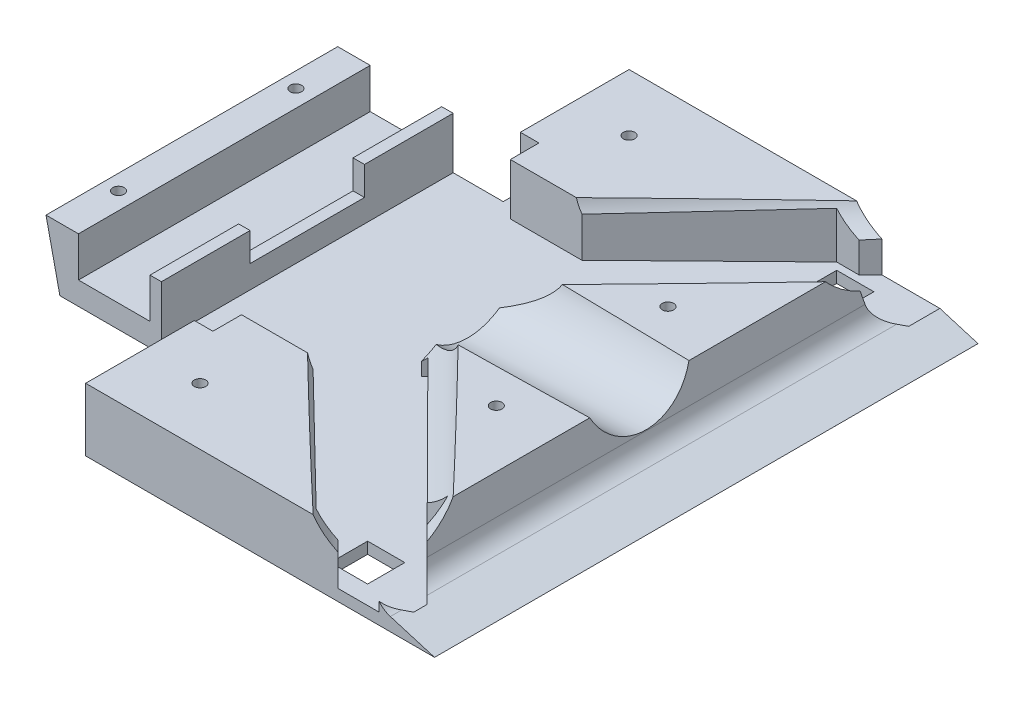
from build123d import *

# Parameters (mm, degrees)
SKETCH1_W           = 95
SKETCH1_H           = 95
BOSS_EXTRUDE1_DEPTH = 50
CUT_EXTRUDE1_DEPTH  = 100
SKETCH3_R           = 9.5
CUT_EXTRUDE2_DEPTH  = 45
CUT_EXTRUDE4_DEPTH  = 45
CUT_EXTRUDE5_DEPTH  = 45
CUT_EXTRUDE6_DEPTH  = 45
CUT_EXTRUDE7_DEPTH  = 45
SKETCH9_R           = 9.5
CUT_EXTRUDE9_DEPTH  = 45
SKETCH11_R          = 9.5
CUT_EXTRUDE10_DEPTH = 45
SKETCH12_W          = 31.985759797
SKETCH12_H          = 95
BOSS_EXTRUDE2_DEPTH = 45
CUT_EXTRUDE11_DEPTH = 100
SKETCH14_R          = 9.5
CUT_EXTRUDE12_DEPTH = 100
SKETCH15_R          = 9.5
CUT_EXTRUDE13_DEPTH = 100
SKETCH16_R          = 9.5
CUT_EXTRUDE14_DEPTH = 100
FILLET2_R           = 4
SKETCH17_W          = 34
SKETCH17_H          = 34
CUT_EXTRUDE16_DEPTH = 22
SKETCH19_W          = 34
SKETCH19_H          = 34
CUT_EXTRUDE17_DEPTH = 22
SKETCH20_W          = 12.5
SKETCH20_H          = 16.5
CUT_EXTRUDE18_DEPTH = 60
CUT_EXTRUDE19_DEPTH = 60
CUT_EXTRUDE20_DEPTH = 100
SKETCH23_W          = 96.786059211
SKETCH23_H          = 3
CUT_EXTRUDE21_DEPTH = 1090
CUT_EXTRUDE23_DEPTH = 9
SKETCH26_W          = 101.242795937
SKETCH26_H          = 23.181109139
CUT_EXTRUDE24_DEPTH = 1212
SKETCH27_W          = 9
SKETCH27_H          = 14
CUT_EXTRUDE25_DEPTH = 9
CUT_EXTRUDE30_DEPTH = 9
SKETCH33_W          = 5
SKETCH33_H          = 5
CUT_EXTRUDE31_DEPTH = 9
SKETCH34_W          = 11.575223562
SKETCH34_H          = 33.130685917
CUT_EXTRUDE32_DEPTH = 9
SKETCH35_W          = 15
SKETCH35_H          = 47
CUT_EXTRUDE33_DEPTH = 9
SKETCH36_W          = 1.386035128
SKETCH36_H          = 33.130685917
CUT_EXTRUDE34_DEPTH = 9
SKETCH37_W          = 2
SKETCH37_H          = 20
CUT_EXTRUDE35_DEPTH = 5
SKETCH38_R          = 1
CUT_EXTRUDE36_DEPTH = 5
SKETCH39_R          = 1
CUT_EXTRUDE37_DEPTH = 5
CUT_EXTRUDE39_DEPTH = 9
CUT_EXTRUDE40_DEPTH = 9
CUT_EXTRUDE41_DEPTH = 9
SKETCH44_W          = 6.5
SKETCH44_H          = 6.5
CUT_EXTRUDE42_DEPTH = 9
SKETCH45_W          = 12
SKETCH45_H          = 57
CUT_EXTRUDE44_DEPTH = 9
CUT_EXTRUDE48_DEPTH = 9


with BuildPart() as part:
    # Sketch1 → Boss-Extrude1 (new body)
    with BuildSketch(Plane(origin=(0, 0, 0), x_dir=(1, 0, 0), z_dir=(0, 1, 0))):
        with Locations((-8.446550514, 2.043801884)):
            Rectangle(SKETCH1_W, SKETCH1_H)
    extrude(amount=BOSS_EXTRUDE1_DEPTH)

    # Sketch2 → Cut-Extrude1 (cut)
    with BuildSketch(Plane.XY.offset(45.456198116)):
        Polygon((39.053449486, 0), (36.353449486, 50), (39.053449486, 50), align=None)
    extrude(amount=-CUT_EXTRUDE1_DEPTH, mode=Mode.SUBTRACT)

    # Sketch3 → Cut-Extrude2 (cut)
    with BuildSketch(Plane(origin=(38.939900735, 2.10275464, 0), x_dir=(0, 0, -1), z_dir=(0.998545181, 0.05392144, 0))):
        with Locations((2.043801884, 13.394181776)):
            Circle(SKETCH3_R)
    extrude(amount=-CUT_EXTRUDE2_DEPTH, mode=Mode.SUBTRACT)

    # Sketch5 → Cut-Extrude4 (cut)
    with BuildSketch(Plane(origin=(0, 50, 0), x_dir=(1, 0, 0), z_dir=(0, 1, 0))):
        Polygon((39.053449486, 49.543801884), (39.053449486, 29.543801884), (19.053449486, 49.543801884), align=None)
        Polygon((39.053449486, -45.456198116), (39.053449486, -25.456198116), (19.053449486, -45.456198116), align=None)
    extrude(amount=-CUT_EXTRUDE4_DEPTH, mode=Mode.SUBTRACT)

    # Sketch6 → Cut-Extrude5 (cut)
    with BuildSketch(Plane(origin=(0, 50, 0), x_dir=(1, 0, 0), z_dir=(0, 1, 0))):
        Polygon((19.053449486, -45.456198116), (12.925569587, -39.328318218), (6.797689689, -45.456198116), align=None)
        Polygon((19.053449486, 49.543801884), (12.925569587, 43.415921985), (6.797689689, 49.543801884), align=None)
    extrude(amount=-CUT_EXTRUDE5_DEPTH, mode=Mode.SUBTRACT)

    # Sketch7 → Cut-Extrude6 (cut)
    with BuildSketch(Plane(origin=(-13.201374315, 0, 13.201374315), x_dir=(0.707106781, 0, 0.707106781), z_dir=(-0.707106781, 0, 0.707106781))):
        Polygon((45.615209271, 5), (42.915209271, 50), (45.615209271, 50), align=None)
    extrude(amount=-CUT_EXTRUDE6_DEPTH, mode=Mode.SUBTRACT)

    # Sketch8 → Cut-Extrude7 (cut)
    with BuildSketch(Plane(origin=(-15.245176199, 0, -15.245176199), x_dir=(-0.707106781, 0, 0.707106781), z_dir=(-0.707106781, 0, -0.707106781))):
        Polygon((-48.505581614, 5), (-45.805581614, 50), (-48.505581614, 50), align=None)
    extrude(amount=-CUT_EXTRUDE7_DEPTH, mode=Mode.SUBTRACT)

    # Sketch9 → Cut-Extrude9 (cut)
    with BuildSketch(Plane(origin=(34.386964646, 2.917830706, -34.386964646), x_dir=(-0.708373873, 0.059677836, -0.70331004), z_dir=(0.705837415, 0.059892291, -0.705837415))):
        with Locations((14.526974541, 11.311121921)):
            Circle(SKETCH9_R)
    extrude(amount=-CUT_EXTRUDE9_DEPTH, mode=Mode.SUBTRACT)

    # Sketch11 → Cut-Extrude10 (cut)
    with BuildSketch(Plane(origin=(32.350494057, 2.745030447, 32.350494057), x_dir=(0.70331004, 0.059677836, -0.708373873), z_dir=(0.705837415, 0.059892291, 0.705837415))):
        with Locations((-10.17752107, 12.964151979)):
            Circle(SKETCH11_R)
    extrude(amount=-CUT_EXTRUDE10_DEPTH, mode=Mode.SUBTRACT)

    # Sketch12 → Boss-Extrude2 (add)
    with BuildSketch(Plane(origin=(0, 5, 0), x_dir=(1, 0, 0), z_dir=(0, 1, 0))):
        with Locations((22.790569588, 2.043801884)):
            Rectangle(SKETCH12_W, SKETCH12_H)
    extrude(amount=BOSS_EXTRUDE2_DEPTH)

    # Sketch13 → Cut-Extrude11 (cut)
    with BuildSketch(Plane.XY.offset(45.456198116)):
        Polygon((39.053449486, 0), (29.053449486, 3), (19.053449486, 50), (49.745275601, 50), align=None)
    extrude(amount=-CUT_EXTRUDE11_DEPTH, mode=Mode.SUBTRACT)

    # Sketch14 → Cut-Extrude12 (cut)
    with BuildSketch(Plane(origin=(-5.994632406, -0.32371015, 0), x_dir=(0, 0, -1), z_dir=(0.998545181, 0.05392144, 0))):
        with Locations((2.043801884, 13.394181776)):
            Circle(SKETCH14_R)
    extrude(amount=CUT_EXTRUDE12_DEPTH, mode=Mode.SUBTRACT)

    # Sketch15 → Cut-Extrude13 (cut)
    with BuildSketch(Plane(origin=(0.587810371, 0.049877364, 0.587810371), x_dir=(0.70331004, 0.059677836, -0.708373873), z_dir=(0.705837415, 0.059892291, 0.705837415))):
        with Locations((-10.17752107, 12.964151979)):
            Circle(SKETCH15_R)
    extrude(amount=CUT_EXTRUDE13_DEPTH, mode=Mode.SUBTRACT)

    # Sketch16 → Cut-Extrude14 (cut)
    with BuildSketch(Plane(origin=(2.62428096, 0.222677624, -2.62428096), x_dir=(-0.708373873, 0.059677836, -0.70331004), z_dir=(0.705837415, 0.059892291, -0.705837415))):
        with Locations((14.526974541, 11.311121921)):
            Circle(SKETCH16_R)
    extrude(amount=CUT_EXTRUDE14_DEPTH, mode=Mode.SUBTRACT)

    # Fillet2
    fillet2_edges = [part.edges().sort_by_distance(p)[0] for p in [
        (29.053449486, 3, -2.043801884),
    ]]
    fillet(fillet2_edges, radius=FILLET2_R)

    # Sketch17 → Cut-Extrude16 (cut)
    with BuildSketch(Plane.XY.offset(45.456198116)):
        with Locations((-38.946550514, 17)):
            Rectangle(SKETCH17_W, SKETCH17_H)
    extrude(amount=-CUT_EXTRUDE16_DEPTH, mode=Mode.SUBTRACT)

    # Sketch19 → Cut-Extrude17 (cut)
    with BuildSketch(Plane(origin=(0, 0, -49.543801884), x_dir=(-1, 0, 0), z_dir=(0, 0, -1))):
        with Locations((38.946550514, 17)):
            Rectangle(SKETCH19_W, SKETCH19_H)
    extrude(amount=-CUT_EXTRUDE17_DEPTH, mode=Mode.SUBTRACT)

    # Sketch20 → Cut-Extrude18 (cut)
    with BuildSketch(Plane.XY.offset(23.456198116)):
        with Locations((-38.946550514, 12.25)):
            Rectangle(SKETCH20_W, SKETCH20_H)
    extrude(amount=-CUT_EXTRUDE18_DEPTH, mode=Mode.SUBTRACT)

    # Sketch21 → Cut-Extrude19 (cut)
    with BuildSketch(Plane.XY.offset(23.456198116)):
        Polygon((-55.946550514, 34), (-48.446550514, 0), (-55.946550514, 0), align=None)
    extrude(amount=-CUT_EXTRUDE19_DEPTH, mode=Mode.SUBTRACT)

    # Sketch22 → Cut-Extrude20 (cut)
    with BuildSketch(Plane.XY.offset(45.456198116)):
        Polygon((16.581652311, 14.417739075), (-57.762384818, 14.417739075), (-57.762384818, 55.877932289), (42.054048577, 55.877932289), (42.054048577, 14.417739075), align=None)
    extrude(amount=-CUT_EXTRUDE20_DEPTH, mode=Mode.SUBTRACT)

    # Sketch23 → Cut-Extrude21 (cut)
    with BuildSketch(Plane.XY.offset(45.456198116)):
        with Locations((-3.233904528, 12.917739075)):
            Rectangle(SKETCH23_W, SKETCH23_H)
    extrude(amount=-CUT_EXTRUDE21_DEPTH, mode=Mode.SUBTRACT)

    # Sketch25 → Cut-Extrude23 (cut)
    with BuildSketch(Plane(origin=(0, 11.417739075, 0), x_dir=(1, 0, 0), z_dir=(0, 1, 0))):
        Polygon((-14.310515386, -14.521541075), (-2.735291824, -14.521541075), (-2.735291824, 7.535798958), (-2.735291824, 18.609144842), (-14.310515386, 18.609144842), (-14.310515386, 7.535798958), align=None)
    extrude(amount=-CUT_EXTRUDE23_DEPTH, mode=Mode.SUBTRACT)

    # Sketch26 → Cut-Extrude24 (cut)
    with BuildSketch(Plane.XY.offset(45.456198116)):
        with Locations((-4.489584995, 22.59055457)):
            Rectangle(SKETCH26_W, SKETCH26_H)
    extrude(amount=-CUT_EXTRUDE24_DEPTH, mode=Mode.SUBTRACT)

    # Sketch27 → Cut-Extrude25 (cut)
    with BuildSketch(Plane(origin=(0, 11, 0), x_dir=(1, 0, 0), z_dir=(0, 1, 0))):
        with Locations((20.851321826, -36.456198116)):
            Rectangle(SKETCH27_W, SKETCH27_H)
        with Locations((20.851321826, 40.543801884)):
            Rectangle(SKETCH27_W, SKETCH27_H)
    extrude(amount=-CUT_EXTRUDE25_DEPTH, mode=Mode.SUBTRACT)

    # Sketch32 → Cut-Extrude30 (cut)
    with BuildSketch(Plane(origin=(0, 11, 0), x_dir=(1, 0, 0), z_dir=(0, 1, 0))):
        Polygon((16.351321826, -43.456198116), (-14.310515386, -13.521541075), (-14.310515386, -8.521541075), (16.351321826, -38.456198116), align=None)
        Polygon((16.351321826, 47.543801884), (-14.310515386, 17.609144842), (-14.310515386, 12.609144842), (16.351321826, 42.543801884), align=None)
    extrude(amount=-CUT_EXTRUDE30_DEPTH, mode=Mode.SUBTRACT)

    # Sketch33 → Cut-Extrude31 (cut)
    with BuildSketch(Plane(origin=(0, 2, 0), x_dir=(1, 0, 0), z_dir=(0, 1, 0))):
        with Locations((20.851321826, -38.956198116)):
            Rectangle(SKETCH33_W, SKETCH33_H)
        with Locations((20.851321826, 43.043801884)):
            Rectangle(SKETCH33_W, SKETCH33_H)
    extrude(amount=-CUT_EXTRUDE31_DEPTH, mode=Mode.SUBTRACT)

    # Sketch34 → Cut-Extrude32 (cut)
    with BuildSketch(Plane(origin=(0, 11, 0), x_dir=(1, 0, 0), z_dir=(0, 1, 0))):
        with Locations((-8.522903605, 2.043801884)):
            Rectangle(SKETCH34_W, SKETCH34_H)
    extrude(amount=-CUT_EXTRUDE32_DEPTH, mode=Mode.SUBTRACT)

    # Sketch35 → Cut-Extrude33 (cut)
    with BuildSketch(Plane(origin=(0, 11, 0), x_dir=(1, 0, 0), z_dir=(0, 1, 0))):
        with Locations((-23.196550514, 2.043801884)):
            Rectangle(SKETCH35_W, SKETCH35_H)
    extrude(amount=-CUT_EXTRUDE33_DEPTH, mode=Mode.SUBTRACT)

    # Sketch36 → Cut-Extrude34 (cut)
    with BuildSketch(Plane(origin=(0, 11, 0), x_dir=(1, 0, 0), z_dir=(0, 1, 0))):
        with Locations((-15.00353295, 2.043801884)):
            Rectangle(SKETCH36_W, SKETCH36_H)
    extrude(amount=-CUT_EXTRUDE34_DEPTH, mode=Mode.SUBTRACT)

    # Sketch37 → Cut-Extrude35 (cut)
    with BuildSketch(Plane(origin=(0, 11, 0), x_dir=(1, 0, 0), z_dir=(0, 1, 0))):
        with Locations((-31.696550514, 2.043801884)):
            Rectangle(SKETCH37_W, SKETCH37_H)
    extrude(amount=-CUT_EXTRUDE35_DEPTH, mode=Mode.SUBTRACT)

    # Sketch38 → Cut-Extrude36 (cut)
    with BuildSketch(Plane(origin=(0, 11, 0), x_dir=(1, 0, 0), z_dir=(0, 1, 0))):
        with Locations((-11.946550514, 39.543801884)):
            Circle(SKETCH38_R)
        with Locations((-11.946550514, -35.456198116)):
            Circle(SKETCH38_R)
        with Locations((17.351321826, 17.043801884)):
            Circle(SKETCH38_R)
        with Locations((17.351321826, -12.956198116)):
            Circle(SKETCH38_R)
    extrude(amount=-CUT_EXTRUDE36_DEPTH, mode=Mode.SUBTRACT)

    # Sketch39 → Cut-Extrude37 (cut)
    with BuildSketch(Plane(origin=(0, 11, 0), x_dir=(1, 0, 0), z_dir=(0, 1, 0))):
        with Locations((-48.196550514, 17.543801884)):
            Circle(SKETCH39_R)
        with Locations((-48.196550514, -13.456198116)):
            Circle(SKETCH39_R)
    extrude(amount=-CUT_EXTRUDE37_DEPTH, mode=Mode.SUBTRACT)

    # Sketch40 → Cut-Extrude39 (cut)
    with BuildSketch(Plane(origin=(0, 11, 0), x_dir=(1, 0, 0), z_dir=(0, 1, 0))):
        Polygon((-15.696550514, 25.543801884), (-2.647181323, 25.543801884), (-2.647181323, -14.269220545), (-2.647181323, -21.456198116), (-15.696550514, -21.456198116), (-15.696550514, -14.269220545), align=None)
    extrude(amount=-CUT_EXTRUDE39_DEPTH, mode=Mode.SUBTRACT)

    # Sketch41 → Cut-Extrude40 (cut)
    with BuildSketch(Plane(origin=(0, 11, 0), x_dir=(1, 0, 0), z_dir=(0, 1, 0))):
        Polygon((16.351321826, 47.543801884), (16.351321826, 40.043801884), (-2.647181323, 21.729242393), (-4.185964744, 23.325490541), align=None)
    extrude(amount=-CUT_EXTRUDE40_DEPTH, mode=Mode.SUBTRACT)

    # Sketch42 → Cut-Extrude41 (cut)
    with BuildSketch(Plane(origin=(0, 11, 0), x_dir=(1, 0, 0), z_dir=(0, 1, 0))):
        Polygon((16.351321826, -43.456198116), (16.351321826, -35.956198116), (-5.334126199, -15.137389867), (-2.787014943, -23.075510057), align=None)
    extrude(amount=-CUT_EXTRUDE41_DEPTH, mode=Mode.SUBTRACT)

    # Sketch44 → Cut-Extrude42 (cut)
    with BuildSketch(Plane(origin=(0, 2, 0), x_dir=(1, 0, 0), z_dir=(0, 1, 0))):
        with Locations((20.851321826, -38.956198116)):
            Rectangle(SKETCH44_W, SKETCH44_H)
        with Locations((20.851321826, 43.043801884)):
            Rectangle(SKETCH44_W, SKETCH44_H)
    extrude(amount=-CUT_EXTRUDE42_DEPTH, mode=Mode.SUBTRACT)

    # Sketch45 → Cut-Extrude44 (cut)
    with BuildSketch(Plane(origin=(0, 11, 0), x_dir=(1, 0, 0), z_dir=(0, 1, 0))):
        with Locations((-24.696550514, 2.043801884)):
            Rectangle(SKETCH45_W, SKETCH45_H)
    extrude(amount=-CUT_EXTRUDE44_DEPTH, mode=Mode.SUBTRACT)

    # Sketch46 → Cut-Extrude48 (cut)
    with BuildSketch(Plane(origin=(0, 11, 0), x_dir=(1, 0, 0), z_dir=(0, 1, 0))):
        Polygon((-9.876963351, -13.247386672), (-2.080342795, -5.487701891), (33.541472148, -41.279075183), (25.744851592, -49.038759964), align=None)
        Polygon((-4.377362605, 22.910744569), (34.655680256, 61.94378743), (42.433854849, 54.165612837), (0.791196724, 12.522954712), (-6.986977869, 4.744780119), (-6.986977869, 20.301129305), align=None)
    extrude(amount=-CUT_EXTRUDE48_DEPTH, mode=Mode.SUBTRACT)


solid = part.part
